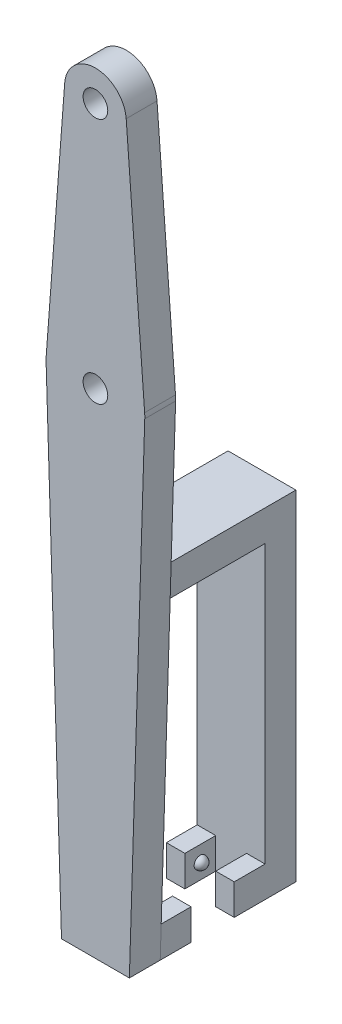
from build123d import *

# Parameters (mm, degrees)
SKETCH1_R           = 2
SKETCH1_R_2         = 5
BOSS_EXTRUDE1_DEPTH = 5
SKETCH2_W           = 11
SKETCH2_H           = 5
BOSS_EXTRUDE2_DEPTH = 5
SKETCH2_3_W         = 5.5
SKETCH2_3_H         = 5
BOSS_EXTRUDE3_DEPTH = 22
SKETCH4_W           = 5
SKETCH4_H           = 5
CUT_EXTRUDE1_DEPTH  = 20
SKETCH6_W           = 11
SKETCH6_H           = 5
BOSS_EXTRUDE4_DEPTH = 50


with BuildPart() as part:
    # Sketch1 → Boss-Extrude1 (new body)
    with BuildSketch(Plane.XY):
        with BuildLine():
            ThreePointArc((7.996084375, 17.249730801), (0, 9.5), (-7.996084375, 17.249730801))
            Line((-7.996084375, 17.249730801), (-5.5, -62.5))
            Line((-5.5, -62.5), (5.5, -62.5))
            Line((5.5, -62.5), (7.996084375, 17.249730801))
        make_face()
        with BuildLine():
            ThreePointArc((7.97746827, 18.1), (0, 25.5), (-7.97746827, 18.1))
            ThreePointArc((-7.97746827, 18.1), (-7.998083236, 17.675112958), (-7.996084375, 17.249730801))
            ThreePointArc((-7.996084375, 17.249730801), (0, 9.5), (7.996084375, 17.249730801))
            ThreePointArc((7.996084375, 17.249730801), (7.999021034, 17.374850086), (8, 17.5))
            ThreePointArc((8, 17.5), (7.994365083, 17.800211458), (7.97746827, 18.1))
        make_face()
        with Locations((0, 17.5)):
            Circle(SKETCH1_R, mode=Mode.SUBTRACT)
        with BuildLine():
            ThreePointArc((5, 57.5), (-0.187632161, 52.503521823), (-4.985917669, 57.875))
            Line((-4.985917669, 57.875), (-7.97746827, 18.1))
            ThreePointArc((-7.97746827, 18.1), (0, 25.5), (7.97746827, 18.1))
            Line((7.97746827, 18.1), (4.985917669, 57.875))
            ThreePointArc((4.985917669, 57.875), (4.996478177, 57.687632161), (5, 57.5))
        make_face()
        with Locations((0, 57.5)):
            Circle(SKETCH1_R_2)
        with Locations((0, 57.5)):
            Circle(SKETCH1_R, mode=Mode.SUBTRACT)
    extrude(amount=BOSS_EXTRUDE1_DEPTH)

    # Sketch2 → Boss-Extrude2 (add)
    with BuildSketch(Plane(origin=(0, 0, 0), x_dir=(-1, 0, 0), z_dir=(0, 0, -1))):
        with Locations((0, -60)):
            Rectangle(SKETCH2_W, SKETCH2_H)
    boss_extrude2 = extrude(amount=BOSS_EXTRUDE2_DEPTH)

    # Sketch2_3 → Boss-Extrude3 (add)
    with BuildSketch(Plane(origin=(0, 0, 0), x_dir=(-1, 0, 0), z_dir=(0, 0, -1))):
        with Locations((-2.75, -10)):
            Rectangle(SKETCH2_3_W, SKETCH2_3_H)
        with Locations((2.75, -10)):
            Rectangle(SKETCH2_3_W, SKETCH2_3_H)
    extrude(amount=BOSS_EXTRUDE3_DEPTH)

    # Sketch4 → Cut-Extrude1 (cut)
    with BuildSketch(Plane(origin=(0, -57.5, 0), x_dir=(1, 0, 0), z_dir=(0, 1, 0))):
        with Locations((0, 2.5)):
            Rectangle(SKETCH4_W, SKETCH4_H)
    cut_extrude1 = extrude(amount=-CUT_EXTRUDE1_DEPTH, mode=Mode.SUBTRACT)

    # Sketch5 → Revolve1 (revolve)
    with BuildSketch(Plane.ZY.offset(-2.5)):
        with BuildLine():
            Line((-3.5, -60), (-1.5, -60))
            ThreePointArc((-1.5, -60), (-2.5, -61), (-3.5, -60))
        make_face()
    revolve1 = revolve(axis=Axis((2.5, -60, 0), (0, 0, -1)))

    # Mirror1: Revolve1 across plane
    add(revolve1.mirror(Plane(origin=(0, 0, 0), x_dir=(0, 0, 1), z_dir=(1, 0, 0))))

    # Sketch6 → Boss-Extrude4 (add)
    with BuildSketch(Plane(origin=(0, -12.5, 0), x_dir=(-1, 0, 0), z_dir=(0, -1, 0))):
        with Locations((0, 19.5)):
            Rectangle(SKETCH6_W, SKETCH6_H)
    extrude(amount=BOSS_EXTRUDE4_DEPTH)

    # Mirror2: Boss-Extrude2, Cut-Extrude1, Revolve1 across plane
    add(boss_extrude2.mirror(Plane(origin=(0, 0, -8.5), x_dir=(1, 0, 0), z_dir=(0, 0, -1))))
    add(cut_extrude1.mirror(Plane(origin=(0, 0, -8.5), x_dir=(1, 0, 0), z_dir=(0, 0, -1))), mode=Mode.SUBTRACT)
    add(revolve1.mirror(Plane(origin=(0, 0, -8.5), x_dir=(1, 0, 0), z_dir=(0, 0, -1))))

    # Mirror2 copy 1 sketch → Mirror2 copy 1 (revolve)
    with BuildSketch(Plane(origin=(-2.5, 0, -17), x_dir=(0, 0, -1), z_dir=(1, 0, 0))):
        with BuildLine():
            Line((-3.5, -60), (-1.5, -60))
            ThreePointArc((-1.5, -60), (-2.5, -61), (-3.5, -60))
        make_face()
    revolve(axis=Axis((-2.5, -60, -17), (0, 0, 1)))


solid = part.part
